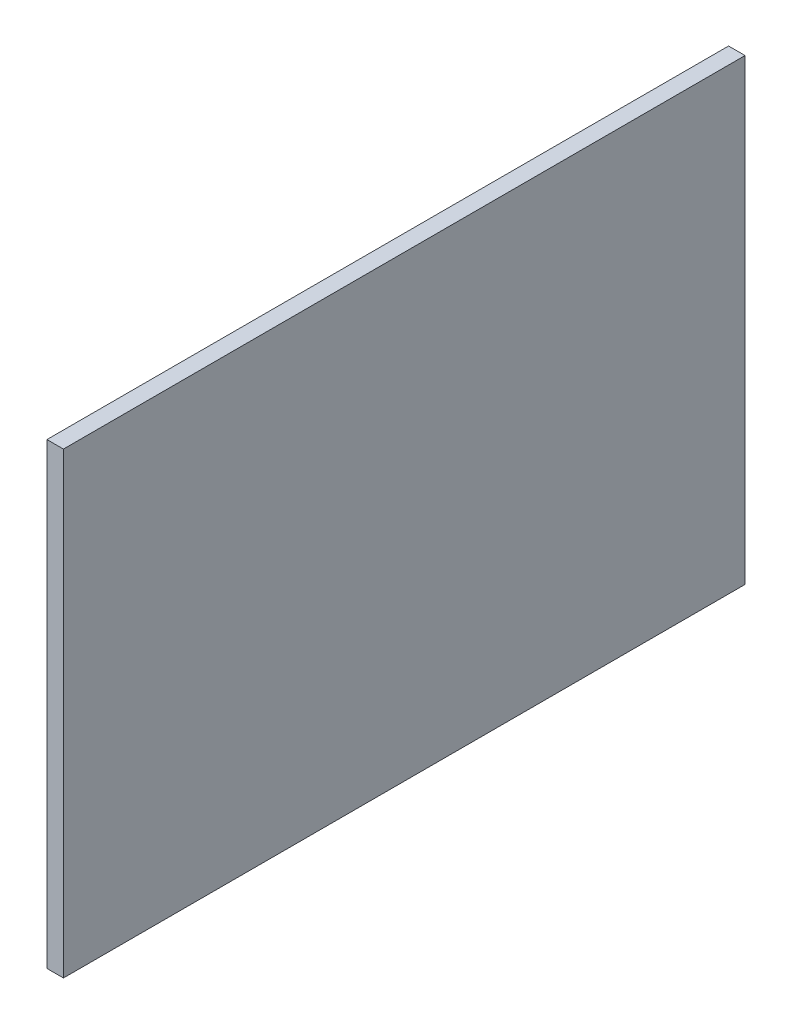
from build123d import *

# Parameters (mm, degrees)
SKETCH1_W           = 744
SKETCH1_H           = 500
BOSS_EXTRUDE1_DEPTH = 18


with BuildPart() as part:
    # Sketch1 → Boss-Extrude1 (new body)
    with BuildSketch(Plane(origin=(0, 0, 0), x_dir=(0, 0, -1), z_dir=(1, 0, 0))):
        with Locations((297.946474068, -215.924952068)):
            Rectangle(SKETCH1_W, SKETCH1_H)
    extrude(amount=BOSS_EXTRUDE1_DEPTH)


solid = part.part
